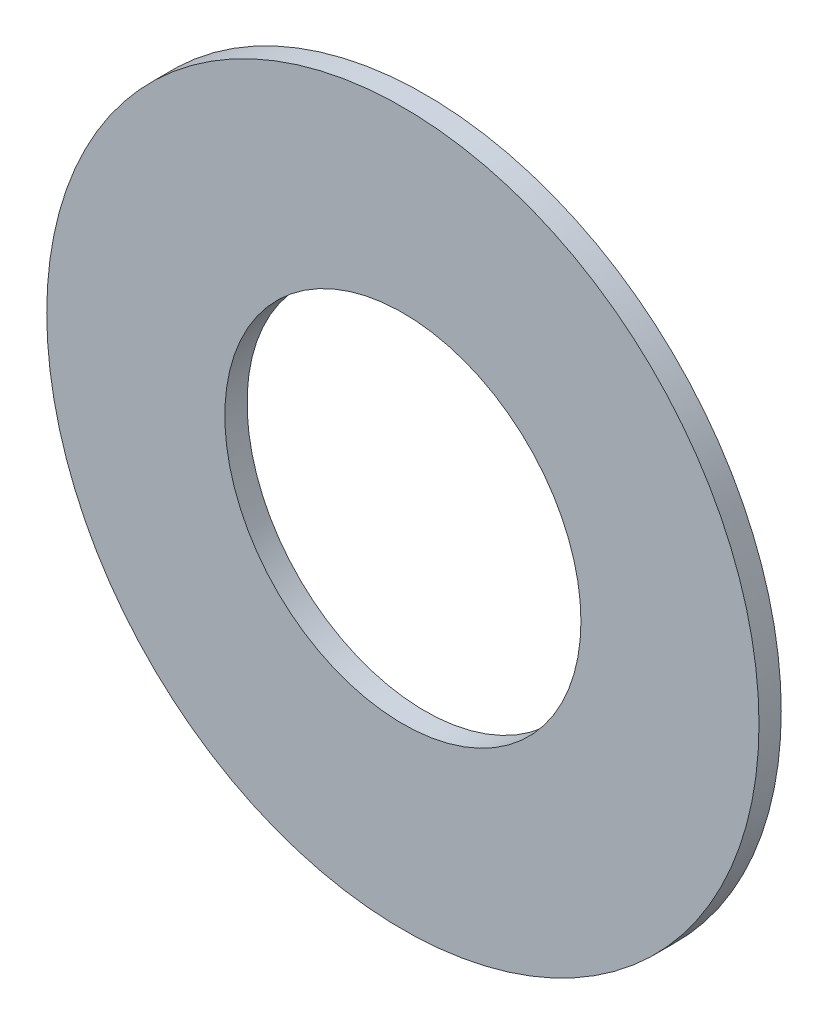
from build123d import *

# Parameters (mm, degrees)
SKETCH_1_R      = 8
SKETCH_1_R_2    = 4
EXTRUDE_1_DEPTH = 0.5


with BuildPart() as part:
    # 草图1 → 凸台-拉伸1 (new body)
    with BuildSketch(Plane.XY):
        Circle(SKETCH_1_R)
        Circle(SKETCH_1_R_2, mode=Mode.SUBTRACT)
    extrude(amount=EXTRUDE_1_DEPTH)


solid = part.part
